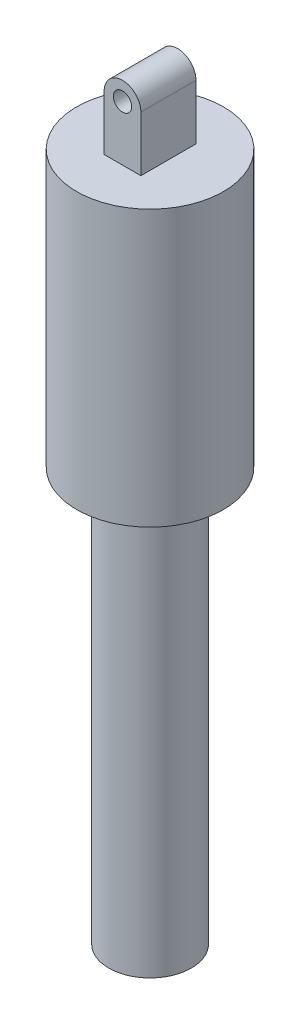
from build123d import *

# Parameters (mm, degrees)
ESBO_O2_R                = 5
RESSALTO_EXTRUS_O1_DEPTH = 15


with BuildPart() as part:
    # Esboço1 → Revolução1 (revolve)
    with BuildSketch(Plane.XY):
        Polygon((0, 150), (40, 150), (40, 0), (22.5, 0), (22.5, -225), (9, -225), (9, 0), (0, 0), align=None)
    revolve(axis=Axis((0, 0, 0), (0, 1, 0)))

    # Esboço2 → Ressalto-extrusão1 (add, symmetric)
    with BuildSketch(Plane.XY):
        with BuildLine():
            Line((10, 150), (10, 180))
            ThreePointArc((10, 180), (0, 190), (-10, 180))
            Line((-10, 180), (-10, 150))
            Line((-10, 150), (10, 150))
        make_face()
        with Locations((0, 180)):
            Circle(ESBO_O2_R, mode=Mode.SUBTRACT)
    extrude(amount=RESSALTO_EXTRUS_O1_DEPTH, both=True)


solid = part.part
